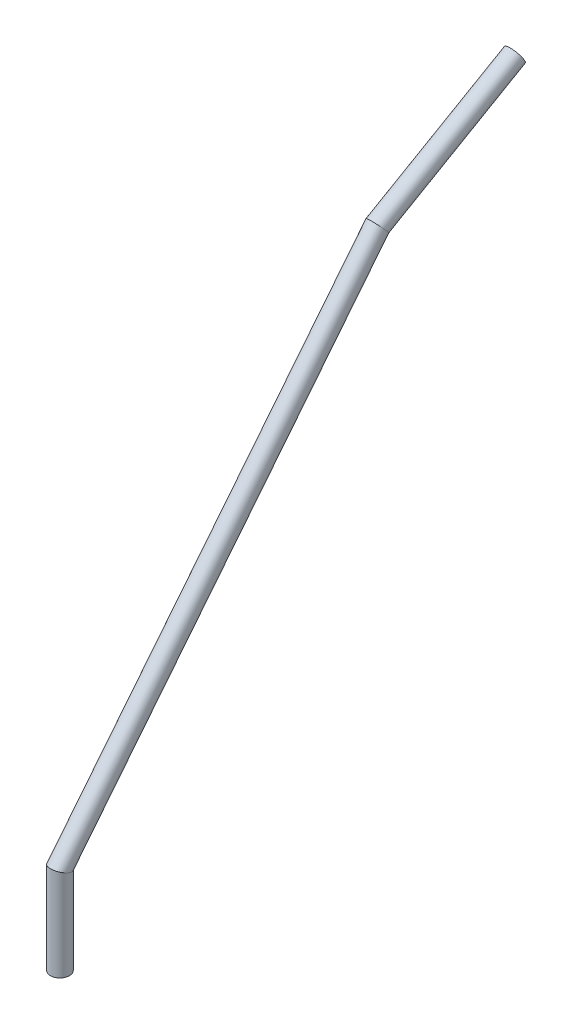
from build123d import *

# Parameters (mm, degrees)
SKETCH2_R          = 4.7625
SKETCH2_R_2        = 3.175
SKETCH11_W         = 4
SKETCH11_H         = 4.7625
CUT_EXTRUDE2_DEPTH = 8


with BuildPart() as part:
    # Sweep2: sweep along a path in Sketch4
    with BuildLine(Plane(origin=(0, 0, 0), x_dir=(0, 0, -1), z_dir=(1, 0, 0))) as sweep2_path:
        Line((8, 0), (8, 45))
        Line((8, 45), (168, 245))
        Line((168, 245), (237.282032303, 285))
    # Sketch2 → Sweep2 (sweep)
    with BuildSketch(Plane(origin=(0, 0, 0), x_dir=(1, 0, 0), z_dir=(0, 1, 0))):
        with Locations((0, 8)):
            Circle(SKETCH2_R)
        with Locations((0, 8)):
            Circle(SKETCH2_R_2, mode=Mode.SUBTRACT)
    sweep(path=sweep2_path.line, transition=Transition.RIGHT)

    # Sketch11 → Cut-Extrude2 (cut)
    with BuildSketch(Plane(origin=(0, 158.996133918, -275.389382153), x_dir=(1, 0, 0), z_dir=(0, 0.5, -0.866025404))):
        with Locations((0, -125.794973927)):
            Rectangle(SKETCH11_W, SKETCH11_H)
    extrude(amount=-CUT_EXTRUDE2_DEPTH, mode=Mode.SUBTRACT)


solid = part.part
